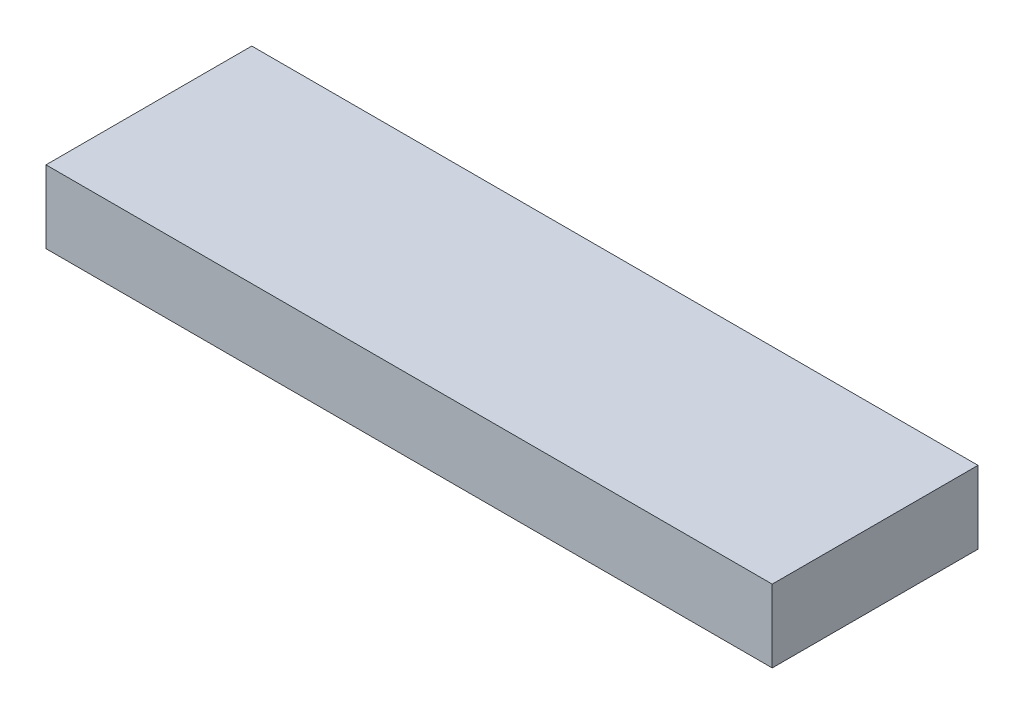
from build123d import *

# Parameters (mm, degrees)
SKETCH1_W           = 0.6
SKETCH1_H           = 0.06
SKETCH1_W_2         = 0.100937657
SKETCH1_H_2         = 0.029243621
SKETCH1_H_3         = 0.02924362
BOSS_EXTRUDE1_DEPTH = 0.15
SKETCH2_W           = 0.6
SKETCH2_H           = 0.06
BOSS_EXTRUDE2_DEPTH = 0.02


with BuildPart() as part:
    # Sketch1 → Boss-Extrude1 (new body)
    with BuildSketch(Plane.XY):
        with Locations((0.3, 0.03)):
            Rectangle(SKETCH1_W, SKETCH1_H)
        with Locations((0.204209788, 0.03132928)):
            Rectangle(SKETCH1_W_2, SKETCH1_H_2, mode=Mode.SUBTRACT)
        with Locations((0.065538428, 0.030385937)):
            Rectangle(SKETCH1_W_2, SKETCH1_H_3, mode=Mode.SUBTRACT)
        with Locations((0.530606325, 0.029442595)):
            Rectangle(SKETCH1_W_2, SKETCH1_H_2, mode=Mode.SUBTRACT)
        with Locations((0.391934965, 0.028499252)):
            Rectangle(SKETCH1_W_2, SKETCH1_H_3, mode=Mode.SUBTRACT)
    extrude(amount=BOSS_EXTRUDE1_DEPTH)

    # Sketch2 → Boss-Extrude2 (add)
    with BuildSketch(Plane.XY.offset(0.15)):
        with Locations((0.3, 0.03)):
            Rectangle(SKETCH2_W, SKETCH2_H)
    extrude(amount=BOSS_EXTRUDE2_DEPTH)


solid = part.part
